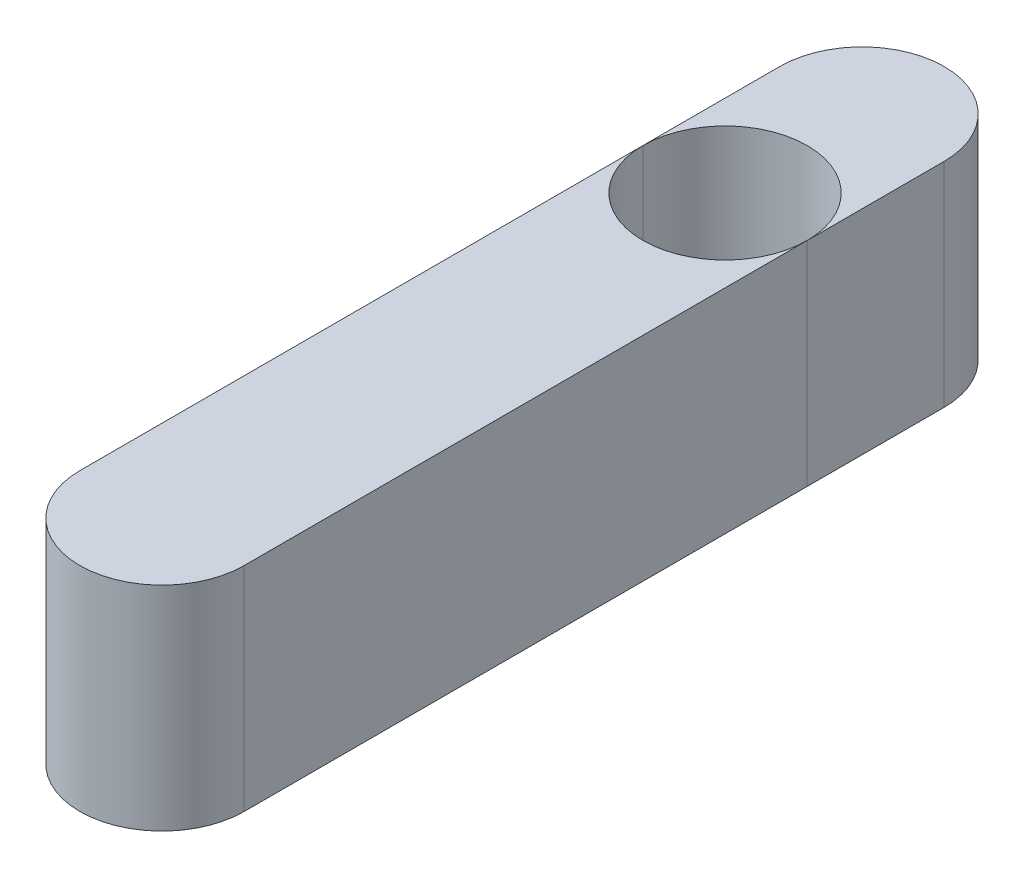
from build123d import *

# Parameters (mm, degrees)
BOSS_EXTRUDE1_DEPTH = 7
SKETCH2_R           = 2.7
CUT_EXTRUDE1_DEPTH  = 7


with BuildPart() as part:
    # Sketch1 → Boss-Extrude1 (new body)
    with BuildSketch(Plane(origin=(0, 0, 0), x_dir=(1, 0, 0), z_dir=(0, 1, 0))):
        with BuildLine():
            Line((-2.7, 0), (-2.7, 23))
            ThreePointArc((-2.7, 23), (0, 25.7), (2.7, 23))
            Line((2.7, 23), (2.7, 0))
            ThreePointArc((2.7, 0), (0, -2.7), (-2.7, 0))
        make_face()
    extrude(amount=BOSS_EXTRUDE1_DEPTH)

    # Sketch2 → Cut-Extrude1 (cut)
    with BuildSketch(Plane(origin=(0, 7, 0), x_dir=(1, 0, 0), z_dir=(0, 1, 0))):
        with Locations((0, 18.5)):
            Circle(SKETCH2_R)
    extrude(amount=-CUT_EXTRUDE1_DEPTH, mode=Mode.SUBTRACT)


solid = part.part
